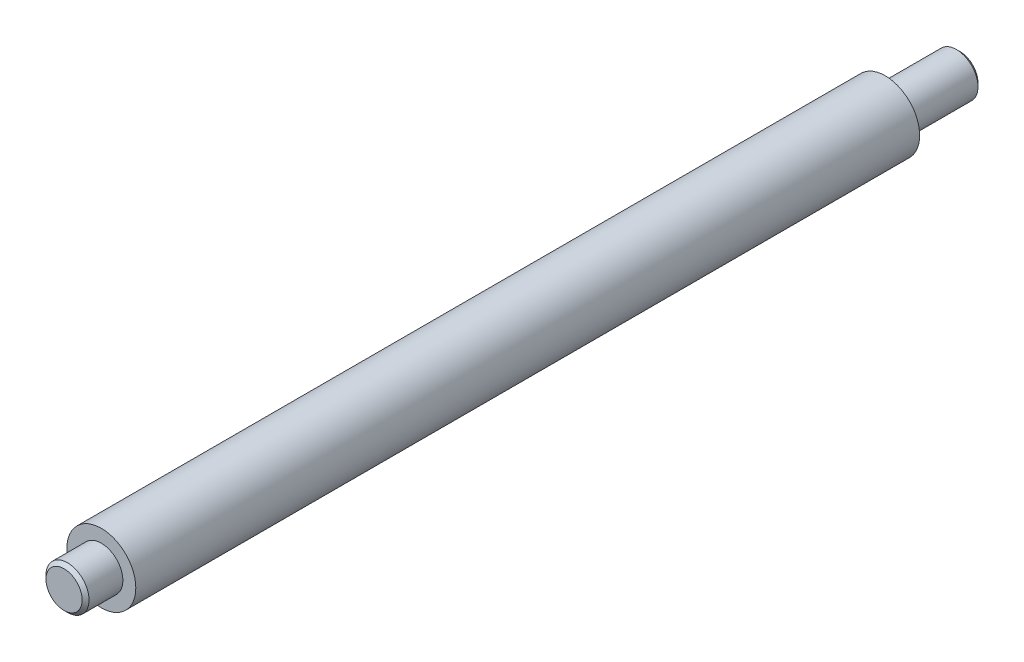
from build123d import *

# Parameters (mm, degrees)
SKETCH1_R           = 12.7
BOSS_EXTRUDE1_DEPTH = 330.2
CUT_EXTRUDE2_START  = -27.5336
SKETCH3_R           = 12.7
SKETCH3_R_2         = 7.9375
CUT_EXTRUDE2_DEPTH  = 27.5336
SKETCH2_R           = 12.7
SKETCH2_R_2         = 7.9375
CUT_EXTRUDE1_DEPTH  = 13.7414
CHAMFER1_SIZE       = 1.27


with BuildPart() as part:
    # Sketch1 → Boss-Extrude1 (new body)
    with BuildSketch(Plane.XY):
        Circle(SKETCH1_R)
    extrude(amount=-BOSS_EXTRUDE1_DEPTH)

    # Sketch3 → Cut-Extrude2 (cut)
    with BuildSketch(Plane(origin=(0, 0, -330.2), x_dir=(-1, 0, 0), z_dir=(0, 0, -1)).offset(CUT_EXTRUDE2_START)):
        Circle(SKETCH3_R)
        Circle(SKETCH3_R_2, mode=Mode.SUBTRACT)
    extrude(amount=CUT_EXTRUDE2_DEPTH, mode=Mode.SUBTRACT)

    # Sketch2 → Cut-Extrude1 (cut)
    with BuildSketch(Plane.XY):
        Circle(SKETCH2_R)
        Circle(SKETCH2_R_2, mode=Mode.SUBTRACT)
    extrude(amount=-CUT_EXTRUDE1_DEPTH, mode=Mode.SUBTRACT)

    # Chamfer1
    chamfer1_edges = [part.edges().sort_by_distance(p)[0] for p in [
        (-7.9375, 0, 0),
        (7.9375, 0, -330.2),
    ]]
    chamfer(chamfer1_edges, length=CHAMFER1_SIZE)


solid = part.part
